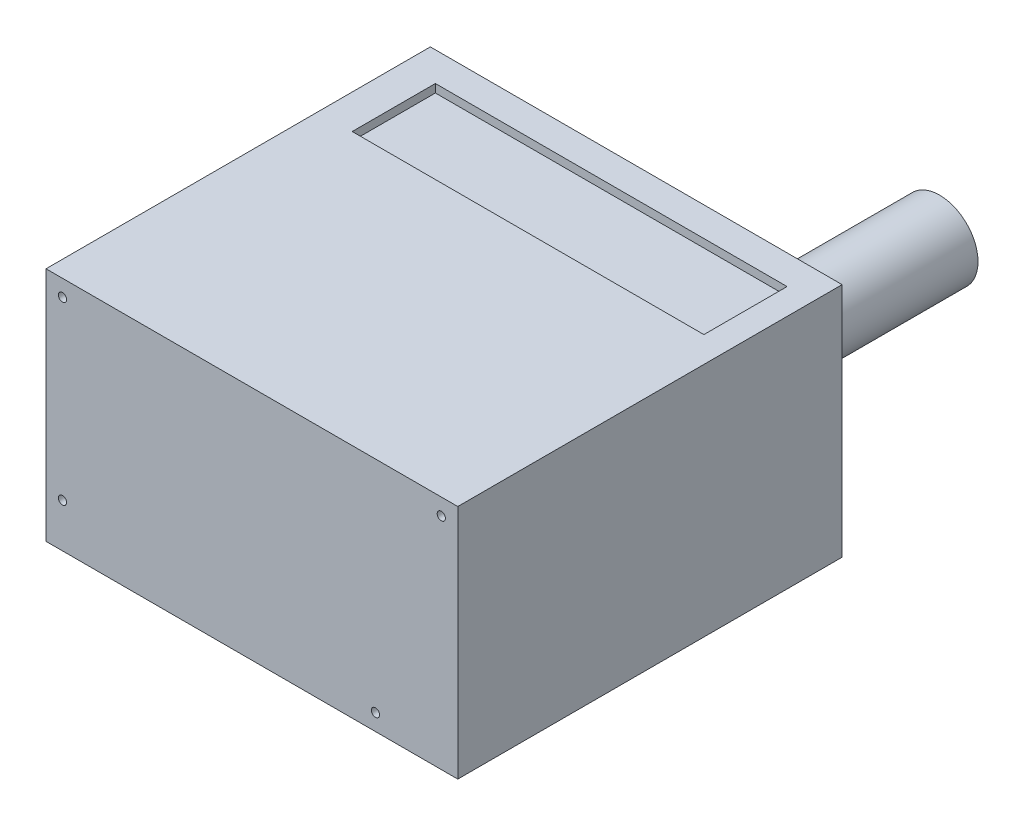
from build123d import *

# Parameters (mm, degrees)
SKETCH1_W           = 150
SKETCH1_H           = 140
BOSS_EXTRUDE1_DEPTH = 86
SKETCH2_R           = 1.5
CUT_EXTRUDE1_DEPTH  = 3
BOTTOM_VENT_W       = 128.112390575
BOTTOM_VENT_H       = 30.300850467
CUT_EXTRUDE2_DEPTH  = 3
SKETCH4_R           = 14
BOSS_EXTRUDE2_DEPTH = 52
SKETCH5_W           = 98.859747303
SKETCH5_H           = 72.009781986
CUT_EXTRUDE3_DEPTH  = 3


with BuildPart() as part:
    # Sketch1 → Boss-Extrude1 (new body)
    with BuildSketch(Plane(origin=(0, 0, 0), x_dir=(1, 0, 0), z_dir=(0, 1, 0))):
        with Locations((75, 70)):
            Rectangle(SKETCH1_W, SKETCH1_H)
    extrude(amount=BOSS_EXTRUDE1_DEPTH)

    # Sketch2 → Cut-Extrude1 (cut)
    with BuildSketch(Plane.XY):
        with Locations((6, 80)):
            Circle(SKETCH2_R)
        with Locations((6, 16)):
            Circle(SKETCH2_R)
        with Locations((120, 6)):
            Circle(SKETCH2_R)
        with Locations((144, 80)):
            Circle(SKETCH2_R)
    extrude(amount=-CUT_EXTRUDE1_DEPTH, mode=Mode.SUBTRACT)

    # bottom vent → Cut-Extrude2 (cut)
    with BuildSketch(Plane(origin=(0, 86, 0), x_dir=(1, 0, 0), z_dir=(0, 1, 0))):
        with Locations((76.529847499, 114.217527718)):
            Rectangle(BOTTOM_VENT_W, BOTTOM_VENT_H)
    extrude(amount=-CUT_EXTRUDE2_DEPTH, mode=Mode.SUBTRACT)

    # Sketch4 → Boss-Extrude2 (add)
    with BuildSketch(Plane(origin=(0, 0, -140), x_dir=(-1, 0, 0), z_dir=(0, 0, -1))):
        with Locations((-133.5, 66)):
            Circle(SKETCH4_R)
    extrude(amount=BOSS_EXTRUDE2_DEPTH)

    # Sketch5 → Cut-Extrude3 (cut)
    with BuildSketch(Plane(origin=(0, 0, -140), x_dir=(-1, 0, 0), z_dir=(0, 0, -1))):
        with Locations((-65.179614688, 41.905186472)):
            Rectangle(SKETCH5_W, SKETCH5_H)
    extrude(amount=-CUT_EXTRUDE3_DEPTH, mode=Mode.SUBTRACT)


solid = part.part
